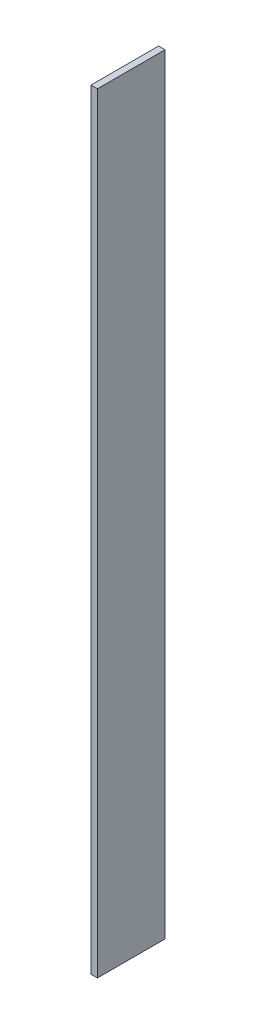
from build123d import *

# Parameters (mm, degrees)
SKETCH1_W           = 12.7
SKETCH1_H           = 144.4625
BOSS_EXTRUDE1_DEPTH = 1.21412


with BuildPart() as part:
    # Sketch1 → Boss-Extrude1 (new body)
    with BuildSketch(Plane(origin=(0, 0, 0), x_dir=(0, 0, -1), z_dir=(1, 0, 0))):
        Rectangle(SKETCH1_W, SKETCH1_H)
    extrude(amount=BOSS_EXTRUDE1_DEPTH)


solid = part.part
